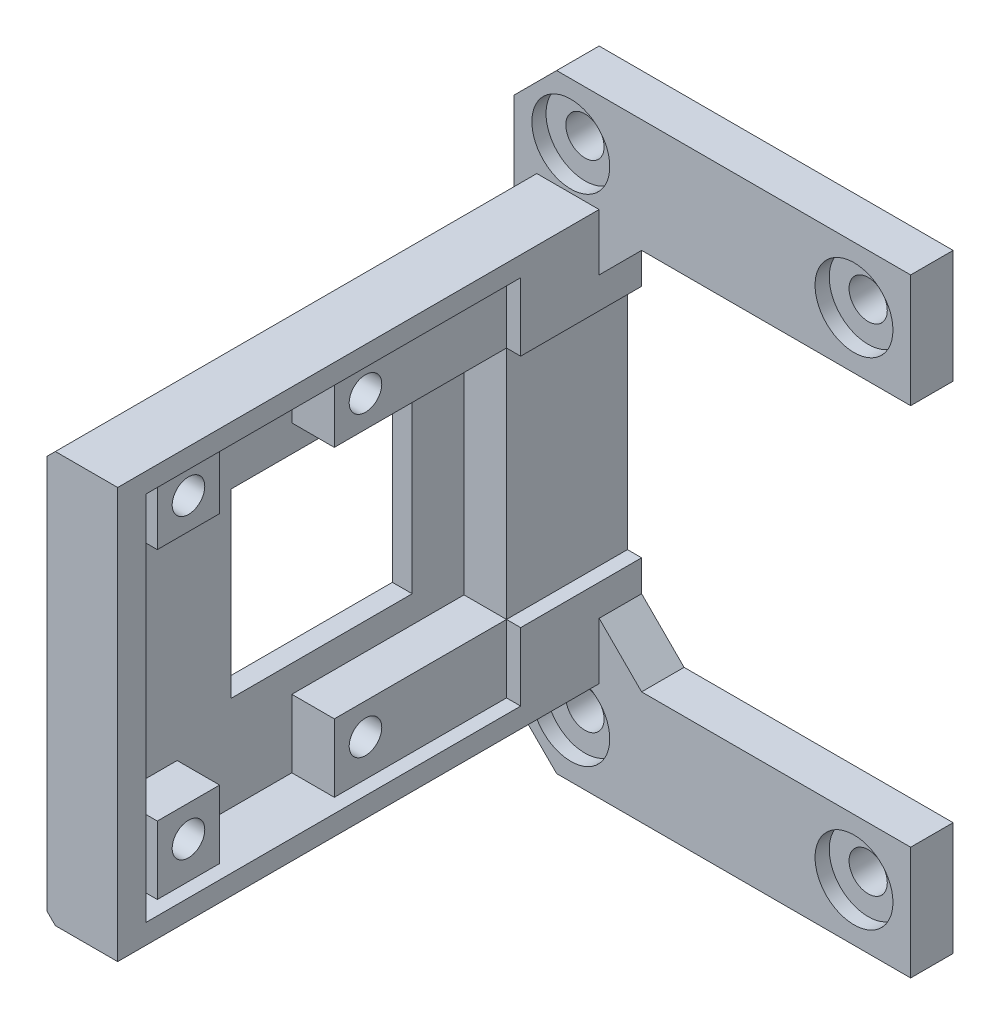
from build123d import *

# Parameters (mm, degrees)
BOSS_EXTRUDE1_DEPTH  = 3
SKETCH3_R            = 1.35
CUT_EXTRUDE1_DEPTH   = 4
SKETCH4_W            = 6
SKETCH4_H            = 27
BOSS_EXTRUDE2_DEPTH  = 32
SKETCH5_R            = 9
CUT_EXTRUDE2_DEPTH   = 29
SKETCH6_W            = 8
SKETCH6_H            = 25
CUT_EXTRUDE3_DEPTH   = 3
SKETCH7_R            = 2.5
SKETCH7_R_2          = 1.65
BOSS_EXTRUDE3_DEPTH  = 3
SKETCH8_R            = 1.65
CUT_EXTRUDE4_DEPTH   = 3
CHAMFER1_SIZE        = 0.6
SKETCH9_R            = 2.75
CUT_EXTRUDE5_DEPTH   = 1
CHAMFER2_SIZE        = 3
CHAMFER3_SIZE        = 3
SKETCH10_W           = 32
SKETCH10_H           = 27
CUT_EXTRUDE6_DEPTH   = 20
SKETCH11_R           = 1.65
BOSS_EXTRUDE5_DEPTH  = 3
BOSS_EXTRUDE6_DEPTH  = 3
SKETCH12_R           = 9
BOSS_EXTRUDE7_DEPTH  = 3
SKETCH15_W           = 25.06
SKETCH15_H           = 26.2
CUT_EXTRUDE7_DEPTH   = 4
SKETCH16_W           = 12.8
SKETCH16_H           = 12.8
CUT_EXTRUDE8_DEPTH   = 3
SKETCH17_W           = 12.16
SKETCH17_H           = 4.8
SKETCH17_W_2         = 4.4
BOSS_EXTRUDE8_DEPTH  = 3
SKETCH18_R           = 1.15
CUT_EXTRUDE9_DEPTH   = 6
SKETCH19_R           = 2
CUT_EXTRUDE11_DEPTH  = 1.8
CUT_EXTRUDE13_DEPTH  = 0.2
SKETCH21_W           = 2.3
SKETCH21_H           = 2.3
CUT_EXTRUDE14_DEPTH  = 0.2
CHAMFER4_SIZE        = 0.6
SKETCH22_W           = 1.4
SKETCH22_H           = 26.2
CUT_EXTRUDE15_DEPTH  = 4
BOSS_EXTRUDE9_DEPTH  = 32
SKETCH24_W           = 8.54
SKETCH24_H           = 16.6
CUT_EXTRUDE16_DEPTH  = 1
BOSS_EXTRUDE10_DEPTH = 2
CHAMFER5_SIZE        = 1


with BuildPart() as part:
    # Sketch2 → Boss-Extrude1 (new body)
    with BuildSketch(Plane.XY):
        Polygon((-65, 21.5), (-37, 21.5), (-37, 13.5), (-59, 13.5), (-59, -13.5), (-37, -13.5), (-37, -21.5), (-65, -21.5), align=None)
    extrude(amount=BOSS_EXTRUDE1_DEPTH)

    # Sketch3 → Cut-Extrude1 (cut, through all)
    with BuildSketch(Plane.XY.offset(3)):
        with Locations((-41, 17.5)):
            Circle(SKETCH3_R)
        with Locations((-61, 17.5)):
            Circle(SKETCH3_R)
        with Locations((-61, -17.5)):
            Circle(SKETCH3_R)
        with Locations((-41, -17.5)):
            Circle(SKETCH3_R)
    extrude(amount=-CUT_EXTRUDE1_DEPTH, mode=Mode.SUBTRACT)

    # Sketch4 → Boss-Extrude2 (add)
    with BuildSketch(Plane.XY.offset(3)):
        with Locations((-62, 0)):
            Rectangle(SKETCH4_W, SKETCH4_H)
    extrude(amount=BOSS_EXTRUDE2_DEPTH)

    # Sketch5 → Cut-Extrude2 (cut, through all)
    with BuildSketch(Plane.ZY.offset(65)):
        with Locations((23, 0)):
            Circle(SKETCH5_R)
    extrude(amount=-CUT_EXTRUDE2_DEPTH, mode=Mode.SUBTRACT)

    # Sketch6 → Cut-Extrude3 (cut)
    with BuildSketch(Plane(origin=(-59, 0, 0), x_dir=(0, 0, -1), z_dir=(1, 0, 0))):
        with Locations((-23, 0)):
            Rectangle(SKETCH6_W, SKETCH6_H)
    extrude(amount=-CUT_EXTRUDE3_DEPTH, mode=Mode.SUBTRACT)

    # Sketch7 → Boss-Extrude3 (add)
    with BuildSketch(Plane(origin=(-59, 0, 0), x_dir=(0, 0, -1), z_dir=(1, 0, 0))):
        with Locations((-30, 10.5)):
            Circle(SKETCH7_R)
        with Locations((-30, 10.5)):
            Circle(SKETCH7_R_2, mode=Mode.SUBTRACT)
        with Locations((-16, 10.5)):
            Circle(SKETCH7_R)
        with Locations((-16, 10.5)):
            Circle(SKETCH7_R_2, mode=Mode.SUBTRACT)
        with Locations((-16, -10.5)):
            Circle(SKETCH7_R)
        with Locations((-16, -10.5)):
            Circle(SKETCH7_R_2, mode=Mode.SUBTRACT)
        with Locations((-30, -10.5)):
            Circle(SKETCH7_R)
        with Locations((-30, -10.5)):
            Circle(SKETCH7_R_2, mode=Mode.SUBTRACT)
    extrude(amount=BOSS_EXTRUDE3_DEPTH)

    # Sketch8 → Cut-Extrude4 (cut)
    with BuildSketch(Plane(origin=(-59, 0, 0), x_dir=(0, 0, -1), z_dir=(1, 0, 0))):
        with Locations((-30, -10.5)):
            Circle(SKETCH8_R)
        with Locations((-16, -10.5)):
            Circle(SKETCH8_R)
        with Locations((-16, 10.5)):
            Circle(SKETCH8_R)
        with Locations((-30, 10.5)):
            Circle(SKETCH8_R)
    extrude(amount=-CUT_EXTRUDE4_DEPTH, mode=Mode.SUBTRACT)

    # Chamfer1
    chamfer1_edges = [part.edges().sort_by_distance(p)[0] for p in [
        (-65, 13.5, 19),
        (-65, -13.5, 19),
    ]]
    chamfer(chamfer1_edges, length=CHAMFER1_SIZE)

    # Sketch9 → Cut-Extrude5 (cut)
    with BuildSketch(Plane.XY.offset(3)):
        with Locations((-61, 17.5)):
            Circle(SKETCH9_R)
        with Locations((-41, 17.5)):
            Circle(SKETCH9_R)
        with Locations((-41, -17.5)):
            Circle(SKETCH9_R)
        with Locations((-61, -17.5)):
            Circle(SKETCH9_R)
    extrude(amount=-CUT_EXTRUDE5_DEPTH, mode=Mode.SUBTRACT)

    # Chamfer2
    chamfer2_edges = [part.edges().sort_by_distance(p)[0] for p in [
        (-59, 13.5, 1.5),
        (-59, -13.5, 1.5),
    ]]
    chamfer(chamfer2_edges, length=CHAMFER2_SIZE)

    # Chamfer3
    chamfer3_edges = [part.edges().sort_by_distance(p)[0] for p in [
        (-65, 21.5, 1.5),
        (-65, -21.5, 1.5),
    ]]
    chamfer(chamfer3_edges, length=CHAMFER3_SIZE)

    # Sketch10 → Cut-Extrude6 (cut)
    with BuildSketch(Plane(origin=(-59, 0, 0), x_dir=(0, 0, -1), z_dir=(1, 0, 0))):
        with Locations((-19, 0)):
            Rectangle(SKETCH10_W, SKETCH10_H)
    extrude(amount=CUT_EXTRUDE6_DEPTH, mode=Mode.SUBTRACT)

    # Sketch11 → Boss-Extrude5 (add)
    with BuildSketch(Plane(origin=(-59, 0, 0), x_dir=(0, 0, -1), z_dir=(1, 0, 0))):
        with Locations((-30, 10.5)):
            Circle(SKETCH11_R)
        with Locations((-16, 10.5)):
            Circle(SKETCH11_R)
        with Locations((-16, -10.5)):
            Circle(SKETCH11_R)
        with Locations((-30, -10.5)):
            Circle(SKETCH11_R)
    extrude(amount=-BOSS_EXTRUDE5_DEPTH)

    # Sketch11_3 → Boss-Extrude6 (add)
    with BuildSketch(Plane(origin=(-59, 0, 0), x_dir=(0, 0, -1), z_dir=(1, 0, 0))):
        with BuildLine():
            ThreePointArc((-27, 8.062257748), (-32, 0), (-27, -8.062257748))
            Line((-27, -8.062257748), (-27, -12.5))
            Line((-27, -12.5), (-19, -12.5))
            Line((-19, -12.5), (-19, -8.062257748))
            ThreePointArc((-19, -8.062257748), (-14, 0), (-19, 8.062257748))
            Line((-19, 8.062257748), (-19, 12.5))
            Line((-19, 12.5), (-27, 12.5))
            Line((-27, 12.5), (-27, 8.062257748))
        make_face()
    extrude(amount=-BOSS_EXTRUDE6_DEPTH)

    # Sketch12 → Boss-Extrude7 (add)
    with BuildSketch(Plane.ZY.offset(62)):
        with Locations((23, 0)):
            Circle(SKETCH12_R)
    extrude(amount=BOSS_EXTRUDE7_DEPTH)

    # Sketch15 → Cut-Extrude7 (cut)
    with BuildSketch(Plane(origin=(-59, 0, 0), x_dir=(0, 0, -1), z_dir=(1, 0, 0))):
        with Locations((-21.07, 0)):
            Rectangle(SKETCH15_W, SKETCH15_H)
    extrude(amount=-CUT_EXTRUDE7_DEPTH, mode=Mode.SUBTRACT)

    # Sketch16 → Cut-Extrude8 (cut, through all)
    with BuildSketch(Plane(origin=(-63, 0, 0), x_dir=(0, 0, -1), z_dir=(1, 0, 0))):
        with Locations((-18.6, 0)):
            Rectangle(SKETCH16_W, SKETCH16_H)
    extrude(amount=-CUT_EXTRUDE8_DEPTH, mode=Mode.SUBTRACT)

    # Sketch17 → Boss-Extrude8 (add)
    with BuildSketch(Plane(origin=(-63, 0, 0), x_dir=(0, 0, -1), z_dir=(1, 0, 0))):
        with Locations((-14.62, -10.7)):
            Rectangle(SKETCH17_W, SKETCH17_H)
        with Locations((-31, -10.7)):
            Rectangle(SKETCH17_W_2, SKETCH17_H)
        with Locations((-31, 10.7)):
            Rectangle(SKETCH17_W_2, SKETCH17_H)
        with Locations((-14.62, 10.7)):
            Rectangle(SKETCH17_W, SKETCH17_H)
    extrude(amount=BOSS_EXTRUDE8_DEPTH)

    # Sketch18 → Cut-Extrude9 (cut, through all)
    with BuildSketch(Plane(origin=(-60, 0, 0), x_dir=(0, 0, -1), z_dir=(1, 0, 0))):
        with Locations((-31, 10.5)):
            Circle(SKETCH18_R)
        with Locations((-18.5, 10.5)):
            Circle(SKETCH18_R)
        with Locations((-18.5, -10.5)):
            Circle(SKETCH18_R)
        with Locations((-31, -10.5)):
            Circle(SKETCH18_R)
    extrude(amount=-CUT_EXTRUDE9_DEPTH, mode=Mode.SUBTRACT)

    # Sketch19 → Cut-Extrude11 (cut)
    with BuildSketch(Plane.ZY.offset(65)):
        with Locations((18.5, 10.5)):
            Circle(SKETCH19_R)
        with Locations((31, 10.5)):
            Circle(SKETCH19_R)
        with Locations((31, -10.5)):
            Circle(SKETCH19_R)
        with Locations((18.5, -10.5)):
            Circle(SKETCH19_R)
    extrude(amount=-CUT_EXTRUDE11_DEPTH, mode=Mode.SUBTRACT)

    # Sketch20 → Cut-Extrude13 (cut)
    with BuildSketch(Plane.ZY.offset(63.2)):
        with BuildLine():
            Line((17.35, 8.863693183), (17.35, 12.136306817))
            ThreePointArc((17.35, 12.136306817), (18.5, 12.5), (19.65, 12.136306817))
            Line((19.65, 12.136306817), (19.65, 8.863693183))
            ThreePointArc((19.65, 8.863693183), (18.5, 8.5), (17.35, 8.863693183))
        make_face()
        with BuildLine():
            Line((29.85, 8.863693183), (29.85, 12.136306817))
            ThreePointArc((29.85, 12.136306817), (31, 12.5), (32.15, 12.136306817))
            Line((32.15, 12.136306817), (32.15, 8.863693183))
            ThreePointArc((32.15, 8.863693183), (31, 8.5), (29.85, 8.863693183))
        make_face()
    cut_extrude13 = extrude(amount=-CUT_EXTRUDE13_DEPTH, mode=Mode.SUBTRACT)

    # Sketch21 → Cut-Extrude14 (cut)
    with BuildSketch(Plane.ZY.offset(63)):
        with Locations((18.5, 10.5)):
            Rectangle(SKETCH21_W, SKETCH21_H)
        with Locations((31, 10.5)):
            Rectangle(SKETCH21_W, SKETCH21_H)
    cut_extrude14 = extrude(amount=-CUT_EXTRUDE14_DEPTH, mode=Mode.SUBTRACT)

    # Mirror1: Cut-Extrude13, Cut-Extrude14 across plane
    add(cut_extrude13.mirror(Plane.ZX), mode=Mode.SUBTRACT)
    add(cut_extrude14.mirror(Plane.ZX), mode=Mode.SUBTRACT)

    # Chamfer4
    chamfer4_edges = [part.edges().sort_by_distance(p)[0] for p in [
        (-65, 0, 25),
        (-65, 6.4, 18.6),
        (-65, 0, 12.2),
        (-65, -6.4, 18.6),
    ]]
    chamfer(chamfer4_edges, length=CHAMFER4_SIZE)

    # Sketch22 → Cut-Extrude15 (cut)
    with BuildSketch(Plane(origin=(-59, 0, 0), x_dir=(0, 0, -1), z_dir=(1, 0, 0))):
        with Locations((-34.3, 0)):
            Rectangle(SKETCH22_W, SKETCH22_H)
    extrude(amount=-CUT_EXTRUDE15_DEPTH, mode=Mode.SUBTRACT)

    # Sketch23 → Boss-Extrude9 (add)
    with BuildSketch(Plane.XY.offset(35)):
        Polygon((-64.4, 13.5), (-63.4, 14.5), (-59, 14.5), (-59, 13.5), align=None)
        Polygon((-59, -13.5), (-64.4, -13.5), (-63.4, -14.5), (-59, -14.5), align=None)
    extrude(amount=-BOSS_EXTRUDE9_DEPTH)

    # Sketch24 → Cut-Extrude16 (cut)
    with BuildSketch(Plane(origin=(-59, 0, 0), x_dir=(0, 0, -1), z_dir=(1, 0, 0))):
        with Locations((-4.27, 0)):
            Rectangle(SKETCH24_W, SKETCH24_H)
    extrude(amount=-CUT_EXTRUDE16_DEPTH, mode=Mode.SUBTRACT)

    # Sketch27 → Boss-Extrude10 (add)
    with BuildSketch(Plane.XY.offset(35)):
        Polygon((-59, 14.5), (-63.4, 14.5), (-65, 12.9), (-65, -12.9), (-63.4, -14.5), (-59, -14.5), align=None)
    extrude(amount=BOSS_EXTRUDE10_DEPTH)

    # Chamfer5
    chamfer5_edges = [part.edges().sort_by_distance(p)[0] for p in [
        (-65, 0, 37),
    ]]
    chamfer(chamfer5_edges, length=CHAMFER5_SIZE)


solid = part.part
